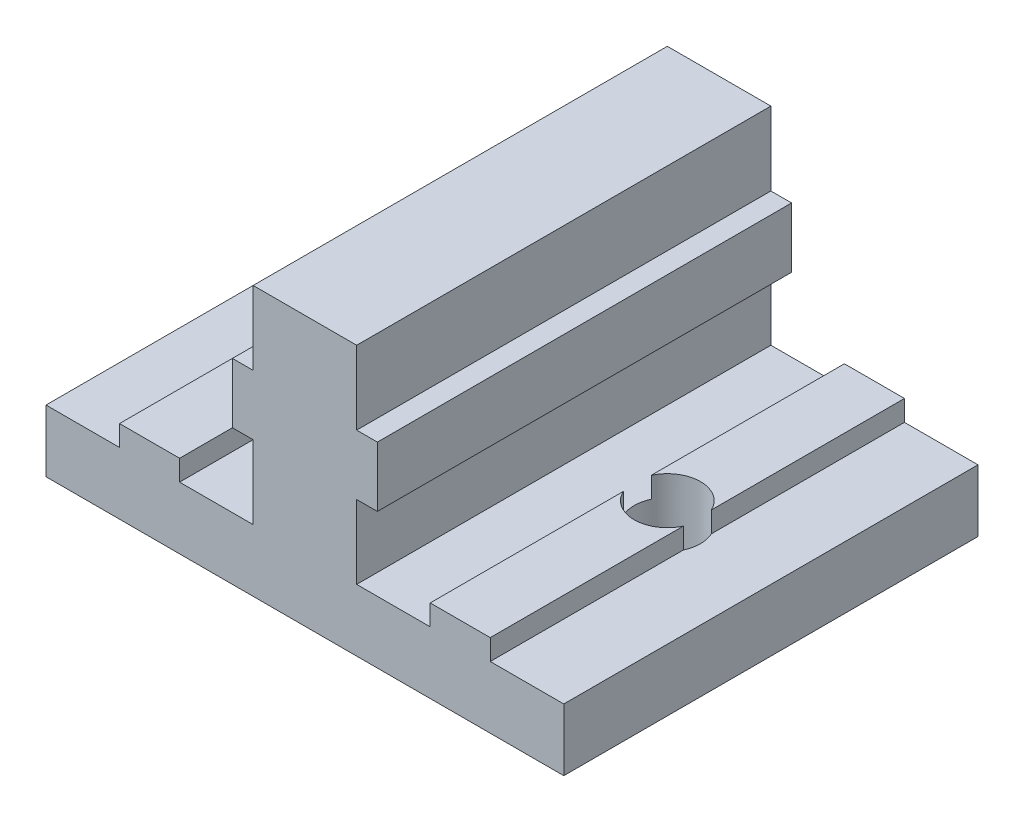
from build123d import *

# Parameters (mm, degrees)
MAIN_DEPTH         = 20
SKETCH1_R          = 1.6
CUT_EXTRUDE1_DEPTH = 14


with BuildPart() as part:
    # Esquisse1 → Main (new body)
    with BuildSketch(Plane.XY):
        Polygon((-12.5, 0), (-12.5, 3), (-8.95, 3), (-8.95, 4), (-6.05, 4), (-6.05, 3), (-2.5, 3), (-2.5, 6.55), (-3.5, 6.55), (-3.5, 9.45), (-2.5, 9.45), (-2.5, 13), (0, 13), (0, 0), align=None)
    main = extrude(amount=MAIN_DEPTH)

    # Symétrie1: Main across plane
    add(main.mirror(Plane(origin=(0, 0, 0), x_dir=(0, 0, 1), z_dir=(1, 0, 0))))

    # Sketch1 → Cut-Extrude1 (cut, through all)
    with BuildSketch(Plane.XZ):
        with Locations((-7.5, 10)):
            Circle(SKETCH1_R)
        with Locations((7.5, 10)):
            Circle(SKETCH1_R)
    extrude(amount=-CUT_EXTRUDE1_DEPTH, mode=Mode.SUBTRACT)


solid = part.part
